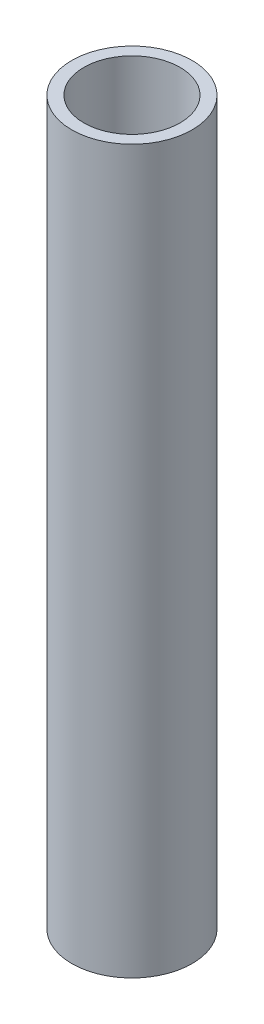
from build123d import *

# Parameters (mm, degrees)
SKETCH2_R           = 5
SKETCH2_R_2         = 4
BOSS_EXTRUDE1_DEPTH = 60


with BuildPart() as part:
    # Sketch2 → Boss-Extrude1 (new body)
    with BuildSketch(Plane(origin=(0, 0, 0), x_dir=(1, 0, 0), z_dir=(0, 1, 0))):
        with Locations((30.34635, 52.561420024)):
            Circle(SKETCH2_R)
        with Locations((30.34635, 52.561420024)):
            Circle(SKETCH2_R_2, mode=Mode.SUBTRACT)
    extrude(amount=BOSS_EXTRUDE1_DEPTH)


solid = part.part
